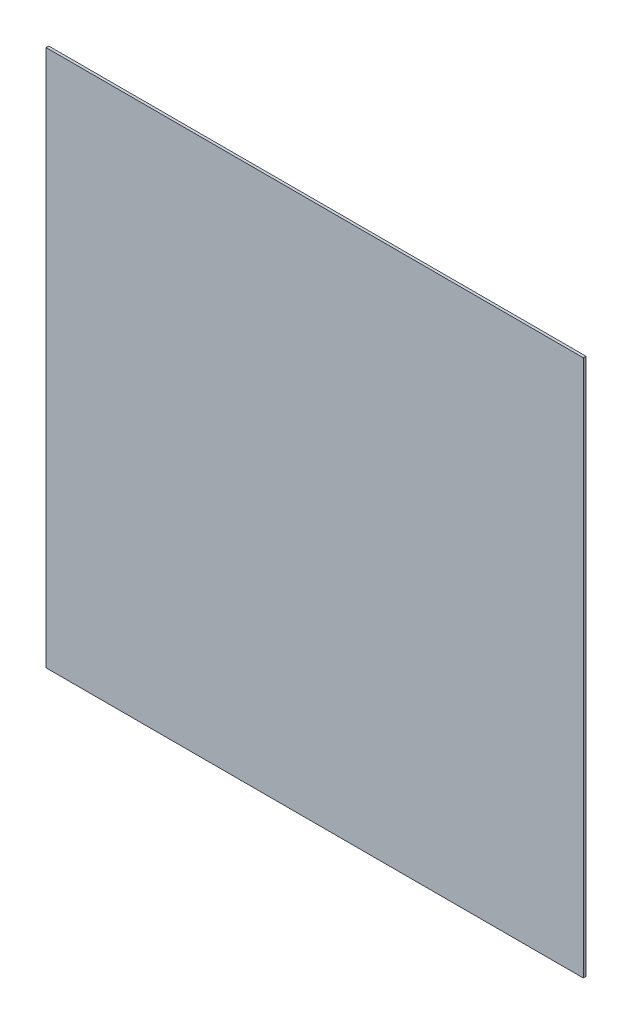
from build123d import *

# Parameters (mm, degrees)
SKETCH_1_W      = 600
SKETCH_1_H      = 3
EXTRUDE_1_DEPTH = 600


with BuildPart() as part:
    # 스케치1 → 보스-돌출1 (new body)
    with BuildSketch(Plane(origin=(0, 0, 0), x_dir=(1, 0, 0), z_dir=(0, 1, 0))):
        with Locations((300, 1.5)):
            Rectangle(SKETCH_1_W, SKETCH_1_H)
    extrude(amount=EXTRUDE_1_DEPTH)


solid = part.part
